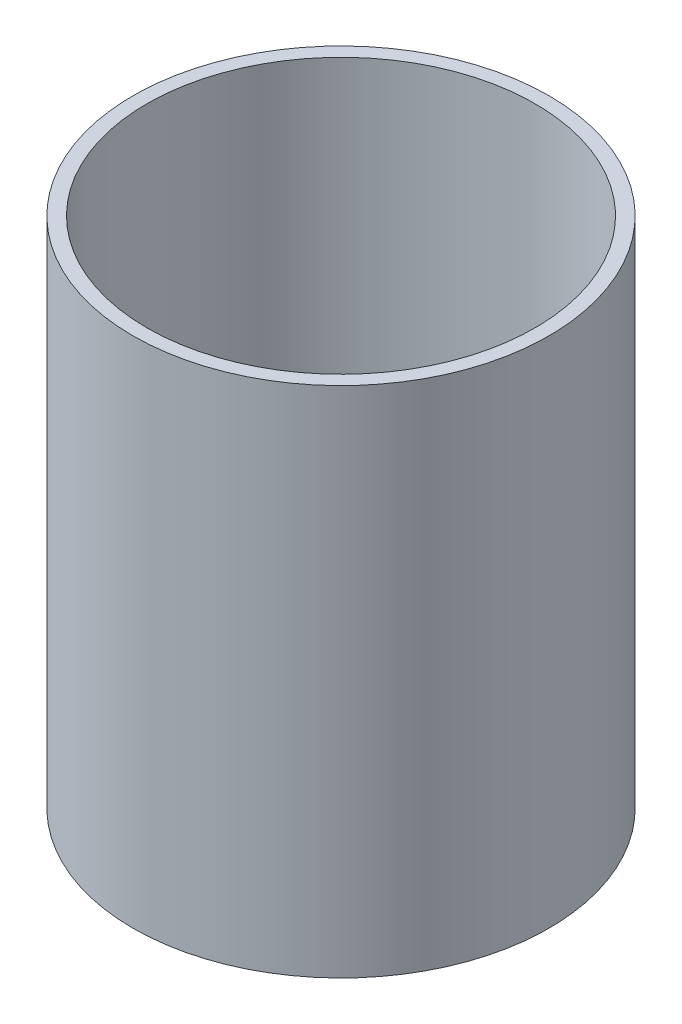
from build123d import *

# Parameters (mm, degrees)
SKETCH1_R           = 15
SKETCH1_R_2         = 14
BOSS_EXTRUDE1_DEPTH = 37


with BuildPart() as part:
    # Sketch1 → Boss-Extrude1 (new body)
    with BuildSketch(Plane(origin=(0, 0, 0), x_dir=(1, 0, 0), z_dir=(0, 1, 0))):
        Circle(SKETCH1_R)
        Circle(SKETCH1_R_2, mode=Mode.SUBTRACT)
    extrude(amount=BOSS_EXTRUDE1_DEPTH)


solid = part.part
